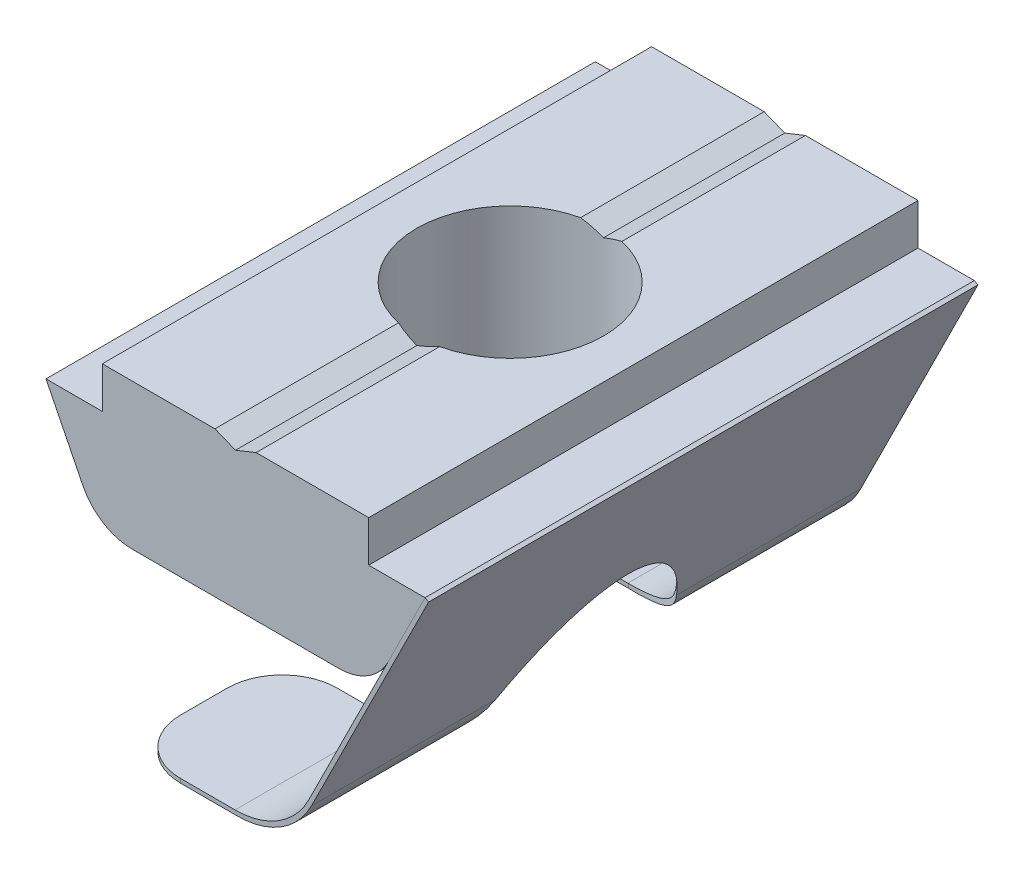
from build123d import *

# Parameters (mm, degrees)
EXTRUDE_1_DEPTH     = 10
EXTRUDE_2_DEPTH     = 10
CUT_EXTRUDE_1_DEPTH = 20
FILLET_1_R          = 2
SKETCH_4_W          = 3.4
SKETCH_4_H          = 11.8


with BuildPart() as part:
    # Эскиз1 → Бобышка-Вытянуть1 (new body, symmetric)
    with BuildSketch(Plane.XY):
        with BuildLine():
            Line((0, 0), (0.75, 0.3))
            Line((0.75, 0.3), (4.85, 0.3))
            Line((4.85, 0.3), (4.85, -1.2))
            Line((4.85, -1.2), (6.9, -1.2))
            Line((6.9, -1.2), (5.557621059, -3.892395626))
            ThreePointArc((5.557621059, -3.892395626), (4.820180183, -4.70070445), (3.767752336, -5))
            Line((3.767752336, -5), (-3.767752336, -5))
            ThreePointArc((-3.767752336, -5), (-4.820180183, -4.70070445), (-5.557621059, -3.892395626))
            Line((-5.557621059, -3.892395626), (-6.9, -1.2))
            Line((-6.9, -1.2), (-4.85, -1.2))
            Line((-4.85, -1.2), (-4.85, 0.3))
            Line((-4.85, 0.3), (-0.75, 0.3))
            Line((-0.75, 0.3), (0, 0))
        make_face()
    extrude(amount=EXTRUDE_1_DEPTH, both=True)

    # Эскиз4 → Отверстие обработанное метчиком M81 (revolve, cut)
    with BuildSketch(Plane(origin=(0, 0.3, 0), x_dir=(0, 0, 1), z_dir=(1, 0, 0))):
        with Locations((1.7, 5.9)):
            Rectangle(SKETCH_4_W, SKETCH_4_H)
    revolve(axis=Axis((0, 6.65, 0), (0, -1, 0)), mode=Mode.SUBTRACT)


with BuildPart() as body_2:
    # Эскиз2 → Бобышка-Вытянуть2 (new body, symmetric)
    with BuildSketch(Plane.XY):
        with BuildLine():
            Line((6.9, -1.2), (2.667743433, -9.688593439))
            ThreePointArc((2.667743433, -9.688593439), (1.561582119, -10.901056675), (-0.017059652, -11.35))
            Line((-0.017059652, -11.35), (-4, -11.35))
            Line((-4, -11.35), (-4, -11.5))
            Line((-4, -11.5), (0.075763165, -11.5))
            ThreePointArc((0.075763165, -11.5), (1.654404936, -11.051056675), (2.760566249, -9.838593439))
            Line((2.760566249, -9.838593439), (7.034240154, -1.266929672))
            Line((7.034240154, -1.266929672), (6.9, -1.2))
        make_face()
    extrude(amount=EXTRUDE_2_DEPTH, both=True)

    # Эскиз3 → Вырез-Вытянуть1 (cut)
    with BuildSketch(Plane.XZ.offset(5)):
        with BuildLine():
            Line((0, 4.3), (-5.557621059, 4.3))
            Line((-5.557621059, 4.3), (-5.557621059, -4.3))
            Line((-5.557621059, -4.3), (0, -4.3))
            ThreePointArc((0, -4.3), (4.3, 0), (0, 4.3))
        make_face()
    extrude(amount=CUT_EXTRUDE_1_DEPTH, mode=Mode.SUBTRACT)

    # Скругление1
    fillet_1_edges = [body_2.edges().sort_by_distance(p)[0] for p in [
        (-4, -11.425, 10),
        (-4, -11.425, 4.3),
        (-4, -11.425, -4.3),
        (-4, -11.425, -10),
    ]]
    fillet(fillet_1_edges, radius=FILLET_1_R)


solid = Compound([part.part, body_2.part])
